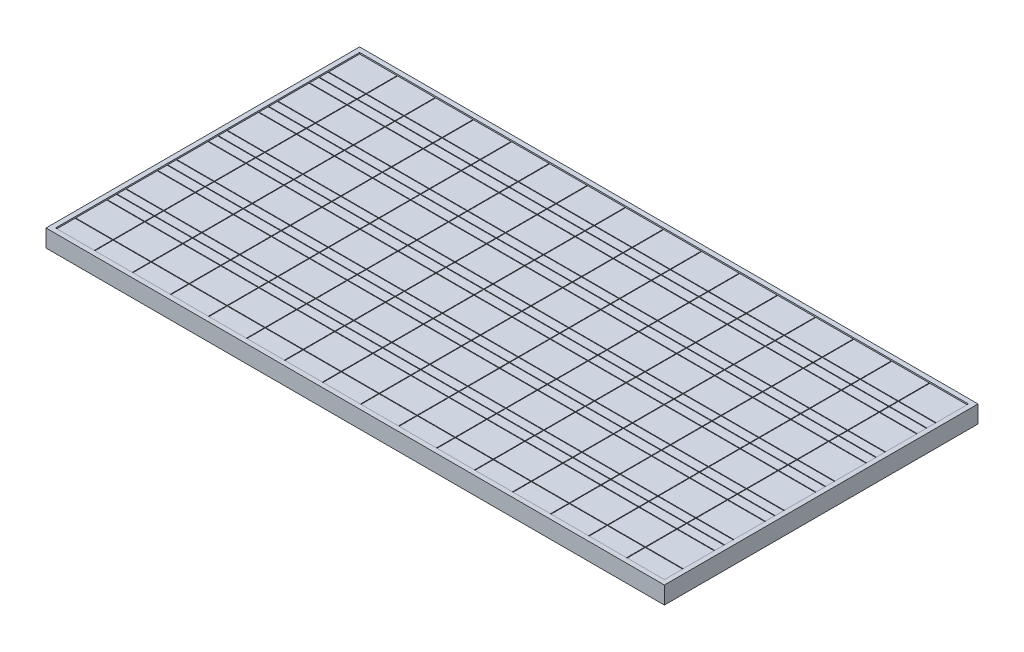
from build123d import *

# Parameters (mm, degrees)
SKETCH1_W           = 1956
SKETCH1_H           = 992
BOSS_EXTRUDE1_DEPTH = 50
SKETCH2_W           = 1876
SKETCH2_H           = 912
CUT_EXTRUDE1_DEPTH  = 25
SKETCH4_W           = 1956
SKETCH4_H           = 992
SKETCH4_W_2         = 1926
SKETCH4_H_2         = 962
BOSS_EXTRUDE3_DEPTH = 5
SKETCH5_W           = 118.25
SKETCH5_H           = 58
SKETCH5_H_2         = 98
SKETCH5_H_3         = 29
SKETCH5_H_4         = 27
BOSS_EXTRUDE4_DEPTH = 2.5


with BuildPart() as part:
    # Sketch1 → Boss-Extrude1 (new body)
    with BuildSketch(Plane(origin=(0, 0, 0), x_dir=(1, 0, 0), z_dir=(0, 1, 0))):
        Rectangle(SKETCH1_W, SKETCH1_H)
    extrude(amount=BOSS_EXTRUDE1_DEPTH)

    # Sketch2 → Cut-Extrude1 (cut)
    with BuildSketch(Plane.XZ):
        Rectangle(SKETCH2_W, SKETCH2_H)
    extrude(amount=-CUT_EXTRUDE1_DEPTH, mode=Mode.SUBTRACT)

    # Sketch4 → Boss-Extrude3 (add)
    with BuildSketch(Plane(origin=(0, 50, 0), x_dir=(1, 0, 0), z_dir=(0, 1, 0))):
        Rectangle(SKETCH4_W, SKETCH4_H)
        Rectangle(SKETCH4_W_2, SKETCH4_H_2, mode=Mode.SUBTRACT)
    extrude(amount=BOSS_EXTRUDE3_DEPTH)


with BuildPart() as body_2:
    # Sketch5 → Boss-Extrude4 (new body)
    with BuildSketch(Plane(origin=(0, 50, 0), x_dir=(1, 0, 0), z_dir=(0, 1, 0))):
        with Locations((-901.875, -450)):
            Rectangle(SKETCH5_W, SKETCH5_H)
        with Locations((-901.875, -370)):
            Rectangle(SKETCH5_W, SKETCH5_H_2)
        with Locations((-901.875, -210)):
            Rectangle(SKETCH5_W, SKETCH5_H_2)
        with Locations((-901.875, -50)):
            Rectangle(SKETCH5_W, SKETCH5_H_2)
        with Locations((-901.875, 110)):
            Rectangle(SKETCH5_W, SKETCH5_H_2)
        with Locations((-901.875, 270)):
            Rectangle(SKETCH5_W, SKETCH5_H_2)
        with Locations((-901.875, 430)):
            Rectangle(SKETCH5_W, SKETCH5_H_2)
        with Locations((-901.875, -304.5)):
            Rectangle(SKETCH5_W, SKETCH5_H_3)
        with Locations((-901.875, -274.5)):
            Rectangle(SKETCH5_W, SKETCH5_H_4)
        with Locations((-901.875, -144.5)):
            Rectangle(SKETCH5_W, SKETCH5_H_3)
        with Locations((-901.875, -114.5)):
            Rectangle(SKETCH5_W, SKETCH5_H_4)
        with Locations((-901.875, 15.5)):
            Rectangle(SKETCH5_W, SKETCH5_H_3)
        with Locations((-901.875, 45.5)):
            Rectangle(SKETCH5_W, SKETCH5_H_4)
        with Locations((-901.875, 175.5)):
            Rectangle(SKETCH5_W, SKETCH5_H_3)
        with Locations((-901.875, 205.5)):
            Rectangle(SKETCH5_W, SKETCH5_H_4)
        with Locations((-901.875, 335.5)):
            Rectangle(SKETCH5_W, SKETCH5_H_3)
        with Locations((-901.875, 365.5)):
            Rectangle(SKETCH5_W, SKETCH5_H_4)
        with Locations((-781.625, -450)):
            Rectangle(SKETCH5_W, SKETCH5_H)
        with Locations((-781.625, -370)):
            Rectangle(SKETCH5_W, SKETCH5_H_2)
        with Locations((-781.625, -304.5)):
            Rectangle(SKETCH5_W, SKETCH5_H_3)
        with Locations((-781.625, -274.5)):
            Rectangle(SKETCH5_W, SKETCH5_H_4)
        with Locations((-781.625, -210)):
            Rectangle(SKETCH5_W, SKETCH5_H_2)
        with Locations((-781.625, -144.5)):
            Rectangle(SKETCH5_W, SKETCH5_H_3)
        with Locations((-781.625, -114.5)):
            Rectangle(SKETCH5_W, SKETCH5_H_4)
        with Locations((-781.625, -50)):
            Rectangle(SKETCH5_W, SKETCH5_H_2)
        with Locations((-781.625, 15.5)):
            Rectangle(SKETCH5_W, SKETCH5_H_3)
        with Locations((-781.625, 45.5)):
            Rectangle(SKETCH5_W, SKETCH5_H_4)
        with Locations((-781.625, 110)):
            Rectangle(SKETCH5_W, SKETCH5_H_2)
        with Locations((-781.625, 175.5)):
            Rectangle(SKETCH5_W, SKETCH5_H_3)
        with Locations((-781.625, 205.5)):
            Rectangle(SKETCH5_W, SKETCH5_H_4)
        with Locations((-781.625, 270)):
            Rectangle(SKETCH5_W, SKETCH5_H_2)
        with Locations((-781.625, 335.5)):
            Rectangle(SKETCH5_W, SKETCH5_H_3)
        with Locations((-781.625, 365.5)):
            Rectangle(SKETCH5_W, SKETCH5_H_4)
        with Locations((-781.625, 430)):
            Rectangle(SKETCH5_W, SKETCH5_H_2)
        with Locations((-661.375, -450)):
            Rectangle(SKETCH5_W, SKETCH5_H)
        with Locations((-661.375, -370)):
            Rectangle(SKETCH5_W, SKETCH5_H_2)
        with Locations((-661.375, -304.5)):
            Rectangle(SKETCH5_W, SKETCH5_H_3)
        with Locations((-661.375, -274.5)):
            Rectangle(SKETCH5_W, SKETCH5_H_4)
        with Locations((-661.375, -210)):
            Rectangle(SKETCH5_W, SKETCH5_H_2)
        with Locations((-661.375, -144.5)):
            Rectangle(SKETCH5_W, SKETCH5_H_3)
        with Locations((-661.375, -114.5)):
            Rectangle(SKETCH5_W, SKETCH5_H_4)
        with Locations((-661.375, -50)):
            Rectangle(SKETCH5_W, SKETCH5_H_2)
        with Locations((-661.375, 15.5)):
            Rectangle(SKETCH5_W, SKETCH5_H_3)
        with Locations((-661.375, 45.5)):
            Rectangle(SKETCH5_W, SKETCH5_H_4)
        with Locations((-661.375, 110)):
            Rectangle(SKETCH5_W, SKETCH5_H_2)
        with Locations((-661.375, 175.5)):
            Rectangle(SKETCH5_W, SKETCH5_H_3)
        with Locations((-661.375, 205.5)):
            Rectangle(SKETCH5_W, SKETCH5_H_4)
        with Locations((-661.375, 270)):
            Rectangle(SKETCH5_W, SKETCH5_H_2)
        with Locations((-661.375, 335.5)):
            Rectangle(SKETCH5_W, SKETCH5_H_3)
        with Locations((-661.375, 365.5)):
            Rectangle(SKETCH5_W, SKETCH5_H_4)
        with Locations((-661.375, 430)):
            Rectangle(SKETCH5_W, SKETCH5_H_2)
        with Locations((-541.125, -450)):
            Rectangle(SKETCH5_W, SKETCH5_H)
        with Locations((-541.125, -370)):
            Rectangle(SKETCH5_W, SKETCH5_H_2)
        with Locations((-541.125, -304.5)):
            Rectangle(SKETCH5_W, SKETCH5_H_3)
        with Locations((-541.125, -274.5)):
            Rectangle(SKETCH5_W, SKETCH5_H_4)
        with Locations((-541.125, -210)):
            Rectangle(SKETCH5_W, SKETCH5_H_2)
        with Locations((-541.125, -144.5)):
            Rectangle(SKETCH5_W, SKETCH5_H_3)
        with Locations((-541.125, -114.5)):
            Rectangle(SKETCH5_W, SKETCH5_H_4)
        with Locations((-541.125, -50)):
            Rectangle(SKETCH5_W, SKETCH5_H_2)
        with Locations((-541.125, 15.5)):
            Rectangle(SKETCH5_W, SKETCH5_H_3)
        with Locations((-541.125, 45.5)):
            Rectangle(SKETCH5_W, SKETCH5_H_4)
        with Locations((-541.125, 110)):
            Rectangle(SKETCH5_W, SKETCH5_H_2)
        with Locations((-541.125, 175.5)):
            Rectangle(SKETCH5_W, SKETCH5_H_3)
        with Locations((-541.125, 205.5)):
            Rectangle(SKETCH5_W, SKETCH5_H_4)
        with Locations((-541.125, 270)):
            Rectangle(SKETCH5_W, SKETCH5_H_2)
        with Locations((-541.125, 335.5)):
            Rectangle(SKETCH5_W, SKETCH5_H_3)
        with Locations((-541.125, 365.5)):
            Rectangle(SKETCH5_W, SKETCH5_H_4)
        with Locations((-541.125, 430)):
            Rectangle(SKETCH5_W, SKETCH5_H_2)
        with Locations((-420.875, -450)):
            Rectangle(SKETCH5_W, SKETCH5_H)
        with Locations((-420.875, -370)):
            Rectangle(SKETCH5_W, SKETCH5_H_2)
        with Locations((-420.875, -304.5)):
            Rectangle(SKETCH5_W, SKETCH5_H_3)
        with Locations((-420.875, -274.5)):
            Rectangle(SKETCH5_W, SKETCH5_H_4)
        with Locations((-420.875, -210)):
            Rectangle(SKETCH5_W, SKETCH5_H_2)
        with Locations((-420.875, -144.5)):
            Rectangle(SKETCH5_W, SKETCH5_H_3)
        with Locations((-420.875, -114.5)):
            Rectangle(SKETCH5_W, SKETCH5_H_4)
        with Locations((-420.875, -50)):
            Rectangle(SKETCH5_W, SKETCH5_H_2)
        with Locations((-420.875, 15.5)):
            Rectangle(SKETCH5_W, SKETCH5_H_3)
        with Locations((-420.875, 45.5)):
            Rectangle(SKETCH5_W, SKETCH5_H_4)
        with Locations((-420.875, 110)):
            Rectangle(SKETCH5_W, SKETCH5_H_2)
        with Locations((-420.875, 175.5)):
            Rectangle(SKETCH5_W, SKETCH5_H_3)
        with Locations((-420.875, 205.5)):
            Rectangle(SKETCH5_W, SKETCH5_H_4)
        with Locations((-420.875, 270)):
            Rectangle(SKETCH5_W, SKETCH5_H_2)
        with Locations((-420.875, 335.5)):
            Rectangle(SKETCH5_W, SKETCH5_H_3)
        with Locations((-420.875, 365.5)):
            Rectangle(SKETCH5_W, SKETCH5_H_4)
        with Locations((-420.875, 430)):
            Rectangle(SKETCH5_W, SKETCH5_H_2)
        with Locations((-300.625, -450)):
            Rectangle(SKETCH5_W, SKETCH5_H)
        with Locations((-300.625, -370)):
            Rectangle(SKETCH5_W, SKETCH5_H_2)
        with Locations((-300.625, -304.5)):
            Rectangle(SKETCH5_W, SKETCH5_H_3)
        with Locations((-300.625, -274.5)):
            Rectangle(SKETCH5_W, SKETCH5_H_4)
        with Locations((-300.625, -210)):
            Rectangle(SKETCH5_W, SKETCH5_H_2)
        with Locations((-300.625, -144.5)):
            Rectangle(SKETCH5_W, SKETCH5_H_3)
        with Locations((-300.625, -114.5)):
            Rectangle(SKETCH5_W, SKETCH5_H_4)
        with Locations((-300.625, -50)):
            Rectangle(SKETCH5_W, SKETCH5_H_2)
        with Locations((-300.625, 15.5)):
            Rectangle(SKETCH5_W, SKETCH5_H_3)
        with Locations((-300.625, 45.5)):
            Rectangle(SKETCH5_W, SKETCH5_H_4)
        with Locations((-300.625, 110)):
            Rectangle(SKETCH5_W, SKETCH5_H_2)
        with Locations((-300.625, 175.5)):
            Rectangle(SKETCH5_W, SKETCH5_H_3)
        with Locations((-300.625, 205.5)):
            Rectangle(SKETCH5_W, SKETCH5_H_4)
        with Locations((-300.625, 270)):
            Rectangle(SKETCH5_W, SKETCH5_H_2)
        with Locations((-300.625, 335.5)):
            Rectangle(SKETCH5_W, SKETCH5_H_3)
        with Locations((-300.625, 365.5)):
            Rectangle(SKETCH5_W, SKETCH5_H_4)
        with Locations((-300.625, 430)):
            Rectangle(SKETCH5_W, SKETCH5_H_2)
        with Locations((-180.375, -450)):
            Rectangle(SKETCH5_W, SKETCH5_H)
        with Locations((-180.375, -370)):
            Rectangle(SKETCH5_W, SKETCH5_H_2)
        with Locations((-180.375, -304.5)):
            Rectangle(SKETCH5_W, SKETCH5_H_3)
        with Locations((-180.375, -274.5)):
            Rectangle(SKETCH5_W, SKETCH5_H_4)
        with Locations((-180.375, -210)):
            Rectangle(SKETCH5_W, SKETCH5_H_2)
        with Locations((-180.375, -144.5)):
            Rectangle(SKETCH5_W, SKETCH5_H_3)
        with Locations((-180.375, -114.5)):
            Rectangle(SKETCH5_W, SKETCH5_H_4)
        with Locations((-180.375, -50)):
            Rectangle(SKETCH5_W, SKETCH5_H_2)
        with Locations((-180.375, 15.5)):
            Rectangle(SKETCH5_W, SKETCH5_H_3)
        with Locations((-180.375, 45.5)):
            Rectangle(SKETCH5_W, SKETCH5_H_4)
        with Locations((-180.375, 110)):
            Rectangle(SKETCH5_W, SKETCH5_H_2)
        with Locations((-180.375, 175.5)):
            Rectangle(SKETCH5_W, SKETCH5_H_3)
        with Locations((-180.375, 205.5)):
            Rectangle(SKETCH5_W, SKETCH5_H_4)
        with Locations((-180.375, 270)):
            Rectangle(SKETCH5_W, SKETCH5_H_2)
        with Locations((-180.375, 335.5)):
            Rectangle(SKETCH5_W, SKETCH5_H_3)
        with Locations((-180.375, 365.5)):
            Rectangle(SKETCH5_W, SKETCH5_H_4)
        with Locations((-180.375, 430)):
            Rectangle(SKETCH5_W, SKETCH5_H_2)
        with Locations((-60.125, -450)):
            Rectangle(SKETCH5_W, SKETCH5_H)
        with Locations((-60.125, -370)):
            Rectangle(SKETCH5_W, SKETCH5_H_2)
        with Locations((-60.125, -304.5)):
            Rectangle(SKETCH5_W, SKETCH5_H_3)
        with Locations((-60.125, -274.5)):
            Rectangle(SKETCH5_W, SKETCH5_H_4)
        with Locations((-60.125, -210)):
            Rectangle(SKETCH5_W, SKETCH5_H_2)
        with Locations((-60.125, -144.5)):
            Rectangle(SKETCH5_W, SKETCH5_H_3)
        with Locations((-60.125, -114.5)):
            Rectangle(SKETCH5_W, SKETCH5_H_4)
        with Locations((-60.125, -50)):
            Rectangle(SKETCH5_W, SKETCH5_H_2)
        with Locations((-60.125, 15.5)):
            Rectangle(SKETCH5_W, SKETCH5_H_3)
        with Locations((-60.125, 45.5)):
            Rectangle(SKETCH5_W, SKETCH5_H_4)
        with Locations((-60.125, 110)):
            Rectangle(SKETCH5_W, SKETCH5_H_2)
        with Locations((-60.125, 175.5)):
            Rectangle(SKETCH5_W, SKETCH5_H_3)
        with Locations((-60.125, 205.5)):
            Rectangle(SKETCH5_W, SKETCH5_H_4)
        with Locations((-60.125, 270)):
            Rectangle(SKETCH5_W, SKETCH5_H_2)
        with Locations((-60.125, 335.5)):
            Rectangle(SKETCH5_W, SKETCH5_H_3)
        with Locations((-60.125, 365.5)):
            Rectangle(SKETCH5_W, SKETCH5_H_4)
        with Locations((-60.125, 430)):
            Rectangle(SKETCH5_W, SKETCH5_H_2)
        with Locations((60.125, -450)):
            Rectangle(SKETCH5_W, SKETCH5_H)
        with Locations((60.125, -370)):
            Rectangle(SKETCH5_W, SKETCH5_H_2)
        with Locations((60.125, -304.5)):
            Rectangle(SKETCH5_W, SKETCH5_H_3)
        with Locations((60.125, -274.5)):
            Rectangle(SKETCH5_W, SKETCH5_H_4)
        with Locations((60.125, -210)):
            Rectangle(SKETCH5_W, SKETCH5_H_2)
        with Locations((60.125, -144.5)):
            Rectangle(SKETCH5_W, SKETCH5_H_3)
        with Locations((60.125, -114.5)):
            Rectangle(SKETCH5_W, SKETCH5_H_4)
        with Locations((60.125, -50)):
            Rectangle(SKETCH5_W, SKETCH5_H_2)
        with Locations((60.125, 15.5)):
            Rectangle(SKETCH5_W, SKETCH5_H_3)
        with Locations((60.125, 45.5)):
            Rectangle(SKETCH5_W, SKETCH5_H_4)
        with Locations((60.125, 110)):
            Rectangle(SKETCH5_W, SKETCH5_H_2)
        with Locations((60.125, 175.5)):
            Rectangle(SKETCH5_W, SKETCH5_H_3)
        with Locations((60.125, 205.5)):
            Rectangle(SKETCH5_W, SKETCH5_H_4)
        with Locations((60.125, 270)):
            Rectangle(SKETCH5_W, SKETCH5_H_2)
        with Locations((60.125, 335.5)):
            Rectangle(SKETCH5_W, SKETCH5_H_3)
        with Locations((60.125, 365.5)):
            Rectangle(SKETCH5_W, SKETCH5_H_4)
        with Locations((60.125, 430)):
            Rectangle(SKETCH5_W, SKETCH5_H_2)
        with Locations((180.375, -450)):
            Rectangle(SKETCH5_W, SKETCH5_H)
        with Locations((180.375, -370)):
            Rectangle(SKETCH5_W, SKETCH5_H_2)
        with Locations((180.375, -304.5)):
            Rectangle(SKETCH5_W, SKETCH5_H_3)
        with Locations((180.375, -274.5)):
            Rectangle(SKETCH5_W, SKETCH5_H_4)
        with Locations((180.375, -210)):
            Rectangle(SKETCH5_W, SKETCH5_H_2)
        with Locations((180.375, -144.5)):
            Rectangle(SKETCH5_W, SKETCH5_H_3)
        with Locations((180.375, -114.5)):
            Rectangle(SKETCH5_W, SKETCH5_H_4)
        with Locations((180.375, -50)):
            Rectangle(SKETCH5_W, SKETCH5_H_2)
        with Locations((180.375, 15.5)):
            Rectangle(SKETCH5_W, SKETCH5_H_3)
        with Locations((180.375, 45.5)):
            Rectangle(SKETCH5_W, SKETCH5_H_4)
        with Locations((180.375, 110)):
            Rectangle(SKETCH5_W, SKETCH5_H_2)
        with Locations((180.375, 175.5)):
            Rectangle(SKETCH5_W, SKETCH5_H_3)
        with Locations((180.375, 205.5)):
            Rectangle(SKETCH5_W, SKETCH5_H_4)
        with Locations((180.375, 270)):
            Rectangle(SKETCH5_W, SKETCH5_H_2)
        with Locations((180.375, 335.5)):
            Rectangle(SKETCH5_W, SKETCH5_H_3)
        with Locations((180.375, 365.5)):
            Rectangle(SKETCH5_W, SKETCH5_H_4)
        with Locations((180.375, 430)):
            Rectangle(SKETCH5_W, SKETCH5_H_2)
        with Locations((300.625, -450)):
            Rectangle(SKETCH5_W, SKETCH5_H)
        with Locations((300.625, -370)):
            Rectangle(SKETCH5_W, SKETCH5_H_2)
        with Locations((300.625, -304.5)):
            Rectangle(SKETCH5_W, SKETCH5_H_3)
        with Locations((300.625, -274.5)):
            Rectangle(SKETCH5_W, SKETCH5_H_4)
        with Locations((300.625, -210)):
            Rectangle(SKETCH5_W, SKETCH5_H_2)
        with Locations((300.625, -144.5)):
            Rectangle(SKETCH5_W, SKETCH5_H_3)
        with Locations((300.625, -114.5)):
            Rectangle(SKETCH5_W, SKETCH5_H_4)
        with Locations((300.625, -50)):
            Rectangle(SKETCH5_W, SKETCH5_H_2)
        with Locations((300.625, 15.5)):
            Rectangle(SKETCH5_W, SKETCH5_H_3)
        with Locations((300.625, 45.5)):
            Rectangle(SKETCH5_W, SKETCH5_H_4)
        with Locations((300.625, 110)):
            Rectangle(SKETCH5_W, SKETCH5_H_2)
        with Locations((300.625, 175.5)):
            Rectangle(SKETCH5_W, SKETCH5_H_3)
        with Locations((300.625, 205.5)):
            Rectangle(SKETCH5_W, SKETCH5_H_4)
        with Locations((300.625, 270)):
            Rectangle(SKETCH5_W, SKETCH5_H_2)
        with Locations((300.625, 335.5)):
            Rectangle(SKETCH5_W, SKETCH5_H_3)
        with Locations((300.625, 365.5)):
            Rectangle(SKETCH5_W, SKETCH5_H_4)
        with Locations((300.625, 430)):
            Rectangle(SKETCH5_W, SKETCH5_H_2)
        with Locations((420.875, -450)):
            Rectangle(SKETCH5_W, SKETCH5_H)
        with Locations((420.875, -370)):
            Rectangle(SKETCH5_W, SKETCH5_H_2)
        with Locations((420.875, -304.5)):
            Rectangle(SKETCH5_W, SKETCH5_H_3)
        with Locations((420.875, -274.5)):
            Rectangle(SKETCH5_W, SKETCH5_H_4)
        with Locations((420.875, -210)):
            Rectangle(SKETCH5_W, SKETCH5_H_2)
        with Locations((420.875, -144.5)):
            Rectangle(SKETCH5_W, SKETCH5_H_3)
        with Locations((420.875, -114.5)):
            Rectangle(SKETCH5_W, SKETCH5_H_4)
        with Locations((420.875, -50)):
            Rectangle(SKETCH5_W, SKETCH5_H_2)
        with Locations((420.875, 15.5)):
            Rectangle(SKETCH5_W, SKETCH5_H_3)
        with Locations((420.875, 45.5)):
            Rectangle(SKETCH5_W, SKETCH5_H_4)
        with Locations((420.875, 110)):
            Rectangle(SKETCH5_W, SKETCH5_H_2)
        with Locations((420.875, 175.5)):
            Rectangle(SKETCH5_W, SKETCH5_H_3)
        with Locations((420.875, 205.5)):
            Rectangle(SKETCH5_W, SKETCH5_H_4)
        with Locations((420.875, 270)):
            Rectangle(SKETCH5_W, SKETCH5_H_2)
        with Locations((420.875, 335.5)):
            Rectangle(SKETCH5_W, SKETCH5_H_3)
        with Locations((420.875, 365.5)):
            Rectangle(SKETCH5_W, SKETCH5_H_4)
        with Locations((420.875, 430)):
            Rectangle(SKETCH5_W, SKETCH5_H_2)
        with Locations((541.125, -450)):
            Rectangle(SKETCH5_W, SKETCH5_H)
        with Locations((541.125, -370)):
            Rectangle(SKETCH5_W, SKETCH5_H_2)
        with Locations((541.125, -304.5)):
            Rectangle(SKETCH5_W, SKETCH5_H_3)
        with Locations((541.125, -274.5)):
            Rectangle(SKETCH5_W, SKETCH5_H_4)
        with Locations((541.125, -210)):
            Rectangle(SKETCH5_W, SKETCH5_H_2)
        with Locations((541.125, -144.5)):
            Rectangle(SKETCH5_W, SKETCH5_H_3)
        with Locations((541.125, -114.5)):
            Rectangle(SKETCH5_W, SKETCH5_H_4)
        with Locations((541.125, -50)):
            Rectangle(SKETCH5_W, SKETCH5_H_2)
        with Locations((541.125, 15.5)):
            Rectangle(SKETCH5_W, SKETCH5_H_3)
        with Locations((541.125, 45.5)):
            Rectangle(SKETCH5_W, SKETCH5_H_4)
        with Locations((541.125, 110)):
            Rectangle(SKETCH5_W, SKETCH5_H_2)
        with Locations((541.125, 175.5)):
            Rectangle(SKETCH5_W, SKETCH5_H_3)
        with Locations((541.125, 205.5)):
            Rectangle(SKETCH5_W, SKETCH5_H_4)
        with Locations((541.125, 270)):
            Rectangle(SKETCH5_W, SKETCH5_H_2)
        with Locations((541.125, 335.5)):
            Rectangle(SKETCH5_W, SKETCH5_H_3)
        with Locations((541.125, 365.5)):
            Rectangle(SKETCH5_W, SKETCH5_H_4)
        with Locations((541.125, 430)):
            Rectangle(SKETCH5_W, SKETCH5_H_2)
        with Locations((661.375, -450)):
            Rectangle(SKETCH5_W, SKETCH5_H)
        with Locations((661.375, -370)):
            Rectangle(SKETCH5_W, SKETCH5_H_2)
        with Locations((661.375, -304.5)):
            Rectangle(SKETCH5_W, SKETCH5_H_3)
        with Locations((661.375, -274.5)):
            Rectangle(SKETCH5_W, SKETCH5_H_4)
        with Locations((661.375, -210)):
            Rectangle(SKETCH5_W, SKETCH5_H_2)
        with Locations((661.375, -144.5)):
            Rectangle(SKETCH5_W, SKETCH5_H_3)
        with Locations((661.375, -114.5)):
            Rectangle(SKETCH5_W, SKETCH5_H_4)
        with Locations((661.375, -50)):
            Rectangle(SKETCH5_W, SKETCH5_H_2)
        with Locations((661.375, 15.5)):
            Rectangle(SKETCH5_W, SKETCH5_H_3)
        with Locations((661.375, 45.5)):
            Rectangle(SKETCH5_W, SKETCH5_H_4)
        with Locations((661.375, 110)):
            Rectangle(SKETCH5_W, SKETCH5_H_2)
        with Locations((661.375, 175.5)):
            Rectangle(SKETCH5_W, SKETCH5_H_3)
        with Locations((661.375, 205.5)):
            Rectangle(SKETCH5_W, SKETCH5_H_4)
        with Locations((661.375, 270)):
            Rectangle(SKETCH5_W, SKETCH5_H_2)
        with Locations((661.375, 335.5)):
            Rectangle(SKETCH5_W, SKETCH5_H_3)
        with Locations((661.375, 365.5)):
            Rectangle(SKETCH5_W, SKETCH5_H_4)
        with Locations((661.375, 430)):
            Rectangle(SKETCH5_W, SKETCH5_H_2)
        with Locations((781.625, -450)):
            Rectangle(SKETCH5_W, SKETCH5_H)
        with Locations((781.625, -370)):
            Rectangle(SKETCH5_W, SKETCH5_H_2)
        with Locations((781.625, -304.5)):
            Rectangle(SKETCH5_W, SKETCH5_H_3)
        with Locations((781.625, -274.5)):
            Rectangle(SKETCH5_W, SKETCH5_H_4)
        with Locations((781.625, -210)):
            Rectangle(SKETCH5_W, SKETCH5_H_2)
        with Locations((781.625, -144.5)):
            Rectangle(SKETCH5_W, SKETCH5_H_3)
        with Locations((781.625, -114.5)):
            Rectangle(SKETCH5_W, SKETCH5_H_4)
        with Locations((781.625, -50)):
            Rectangle(SKETCH5_W, SKETCH5_H_2)
        with Locations((781.625, 15.5)):
            Rectangle(SKETCH5_W, SKETCH5_H_3)
        with Locations((781.625, 45.5)):
            Rectangle(SKETCH5_W, SKETCH5_H_4)
        with Locations((781.625, 110)):
            Rectangle(SKETCH5_W, SKETCH5_H_2)
        with Locations((781.625, 175.5)):
            Rectangle(SKETCH5_W, SKETCH5_H_3)
        with Locations((781.625, 205.5)):
            Rectangle(SKETCH5_W, SKETCH5_H_4)
        with Locations((781.625, 270)):
            Rectangle(SKETCH5_W, SKETCH5_H_2)
        with Locations((781.625, 335.5)):
            Rectangle(SKETCH5_W, SKETCH5_H_3)
        with Locations((781.625, 365.5)):
            Rectangle(SKETCH5_W, SKETCH5_H_4)
        with Locations((781.625, 430)):
            Rectangle(SKETCH5_W, SKETCH5_H_2)
        with Locations((901.875, -450)):
            Rectangle(SKETCH5_W, SKETCH5_H)
        with Locations((901.875, -370)):
            Rectangle(SKETCH5_W, SKETCH5_H_2)
        with Locations((901.875, -304.5)):
            Rectangle(SKETCH5_W, SKETCH5_H_3)
        with Locations((901.875, -274.5)):
            Rectangle(SKETCH5_W, SKETCH5_H_4)
        with Locations((901.875, -210)):
            Rectangle(SKETCH5_W, SKETCH5_H_2)
        with Locations((901.875, -144.5)):
            Rectangle(SKETCH5_W, SKETCH5_H_3)
        with Locations((901.875, -114.5)):
            Rectangle(SKETCH5_W, SKETCH5_H_4)
        with Locations((901.875, -50)):
            Rectangle(SKETCH5_W, SKETCH5_H_2)
        with Locations((901.875, 15.5)):
            Rectangle(SKETCH5_W, SKETCH5_H_3)
        with Locations((901.875, 45.5)):
            Rectangle(SKETCH5_W, SKETCH5_H_4)
        with Locations((901.875, 110)):
            Rectangle(SKETCH5_W, SKETCH5_H_2)
        with Locations((901.875, 175.5)):
            Rectangle(SKETCH5_W, SKETCH5_H_3)
        with Locations((901.875, 205.5)):
            Rectangle(SKETCH5_W, SKETCH5_H_4)
        with Locations((901.875, 270)):
            Rectangle(SKETCH5_W, SKETCH5_H_2)
        with Locations((901.875, 335.5)):
            Rectangle(SKETCH5_W, SKETCH5_H_3)
        with Locations((901.875, 365.5)):
            Rectangle(SKETCH5_W, SKETCH5_H_4)
        with Locations((901.875, 430)):
            Rectangle(SKETCH5_W, SKETCH5_H_2)
    extrude(amount=BOSS_EXTRUDE4_DEPTH)


solid = Compound([part.part, body_2.part])
